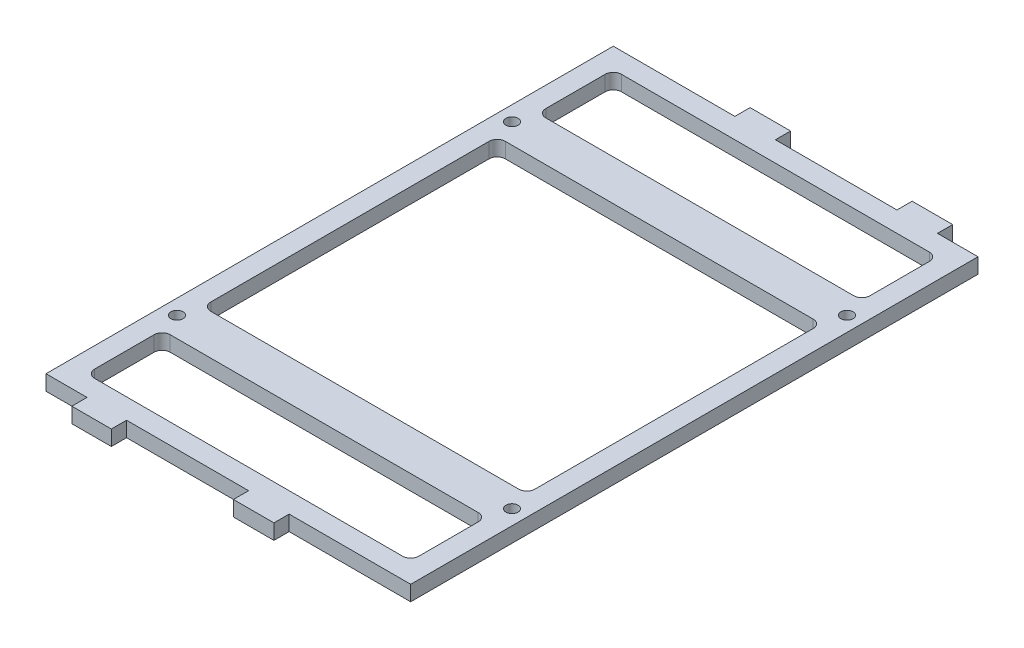
from build123d import *

# Parameters (mm, degrees)
SKETCH1_W                 = 114.3
SKETCH1_H                 = 177.8
SKETCH1_W_2               = 101.6
SKETCH1_H_2               = 165.1
BOSS_EXTRUDE1_DEPTH       = 4.7625
SKETCH2_W                 = 12.38677804
SKETCH2_H                 = 4.7625
SKETCH2_W_2               = 12.7
BOSS_EXTRUDE2_DEPTH       = 4.7625
SKETCH3_W                 = 12.7
SKETCH3_H                 = 4.7625
BOSS_EXTRUDE3_DEPTH       = 4.7625
FILLET1_R                 = 2.54
SKETCH4_W                 = 114.3
SKETCH4_H                 = 12.7
BOSS_EXTRUDE4_DEPTH       = 4.7625
F_6_CLEARANCE_HOLE1_D     = 3.7973
F_6_CLEARANCE_HOLE1_DEPTH = 25.4
F_6_CLEARANCE_HOLE1_TIP   = 1.140824014
FILLET2_R                 = 2.54


with BuildPart() as part:
    # Sketch1 → Boss-Extrude1 (new body)
    with BuildSketch(Plane(origin=(0, 0, 0), x_dir=(1, 0, 0), z_dir=(0, 1, 0))):
        Rectangle(SKETCH1_W, SKETCH1_H)
        Rectangle(SKETCH1_W_2, SKETCH1_H_2, mode=Mode.SUBTRACT)
    extrude(amount=BOSS_EXTRUDE1_DEPTH)

    # Sketch2 → Boss-Extrude2 (add)
    with BuildSketch(Plane.XY.offset(88.9)):
        with Locations((-38.1, 2.38125)):
            Rectangle(SKETCH2_W, SKETCH2_H)
        with Locations((12.7, 2.38125)):
            Rectangle(SKETCH2_W_2, SKETCH2_H)
    extrude(amount=BOSS_EXTRUDE2_DEPTH)

    # Sketch3 → Boss-Extrude3 (add)
    with BuildSketch(Plane(origin=(0, 0, -88.9), x_dir=(-1, 0, 0), z_dir=(0, 0, -1))):
        with Locations((-38.1, 2.38125)):
            Rectangle(SKETCH3_W, SKETCH3_H)
        with Locations((12.7, 2.38125)):
            Rectangle(SKETCH3_W, SKETCH3_H)
    extrude(amount=BOSS_EXTRUDE3_DEPTH)

    # Fillet1
    fillet1_edges = [part.edges().sort_by_distance(p)[0] for p in [
        (50.8, 2.38125, 82.55),
        (50.8, 2.38125, -82.55),
        (-50.8, 2.38125, -82.55),
        (-50.8, 2.38125, 82.55),
    ]]
    fillet(fillet1_edges, radius=FILLET1_R)

    # Sketch4 → Boss-Extrude4 (add)
    with BuildSketch(Plane(origin=(0, 4.7625, 0), x_dir=(1, 0, 0), z_dir=(0, 1, 0))):
        with Locations((0, 52.5)):
            Rectangle(SKETCH4_W, SKETCH4_H)
        with Locations((0, -52.5)):
            Rectangle(SKETCH4_W, SKETCH4_H)
    extrude(amount=-BOSS_EXTRUDE4_DEPTH)

    # #6 Clearance Hole1
    with Locations(Plane(origin=(0, 4.7625, 0), x_dir=(-1, 0, 0), z_dir=(0, 1, 0))):
        with Locations((52.5, -52.5), (-52.5, -52.5), (52.5, 52.5), (-52.5, 52.5)):
            Hole(F_6_CLEARANCE_HOLE1_D / 2, depth=F_6_CLEARANCE_HOLE1_DEPTH)
            with Locations((0, 0, -(F_6_CLEARANCE_HOLE1_DEPTH + F_6_CLEARANCE_HOLE1_TIP / 2))):  # 118° drill point
                Cone(0, F_6_CLEARANCE_HOLE1_D / 2, F_6_CLEARANCE_HOLE1_TIP, mode=Mode.SUBTRACT)

    # Fillet2
    fillet2_edges = [part.edges().sort_by_distance(p)[0] for p in [
        (-50.8, 2.38125, -46.15),
        (-50.8, 2.38125, -58.85),
        (50.8, 2.38125, -58.85),
        (50.8, 2.38125, -46.15),
        (-50.8, 2.38125, 58.85),
        (-50.8, 2.38125, 46.15),
        (50.8, 2.38125, 46.15),
        (50.8, 2.38125, 58.85),
    ]]
    fillet(fillet2_edges, radius=FILLET2_R)


solid = part.part
